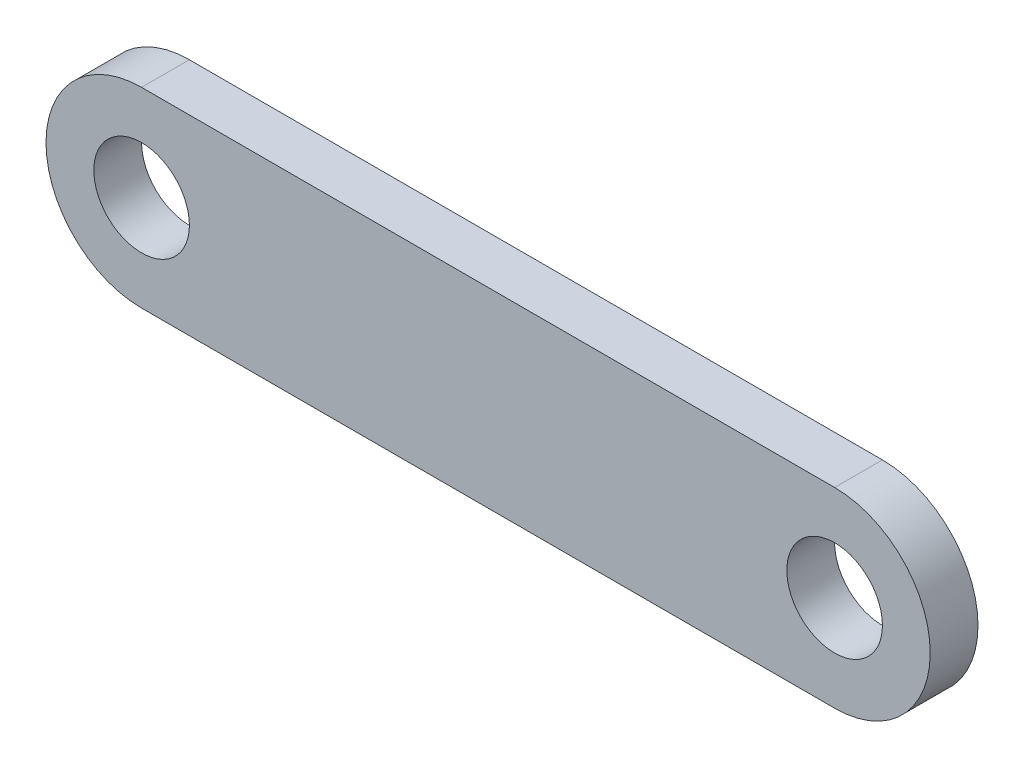
from build123d import *

# Parameters (mm, degrees)
SKETCH1_R           = 2.54
BOSS_EXTRUDE1_DEPTH = 2.54


with BuildPart() as part:
    # Sketch1 → Boss-Extrude1 (new body)
    with BuildSketch(Plane.XY):
        with BuildLine():
            Line((0, 5.08), (36.83, 5.08))
            ThreePointArc((36.83, 5.08), (41.91, 0), (36.83, -5.08))
            Line((36.83, -5.08), (0, -5.08))
            ThreePointArc((0, -5.08), (-5.08, 0), (0, 5.08))
        make_face()
        Circle(SKETCH1_R, mode=Mode.SUBTRACT)
        with Locations((36.83, 0)):
            Circle(SKETCH1_R, mode=Mode.SUBTRACT)
    extrude(amount=BOSS_EXTRUDE1_DEPTH)


solid = part.part
